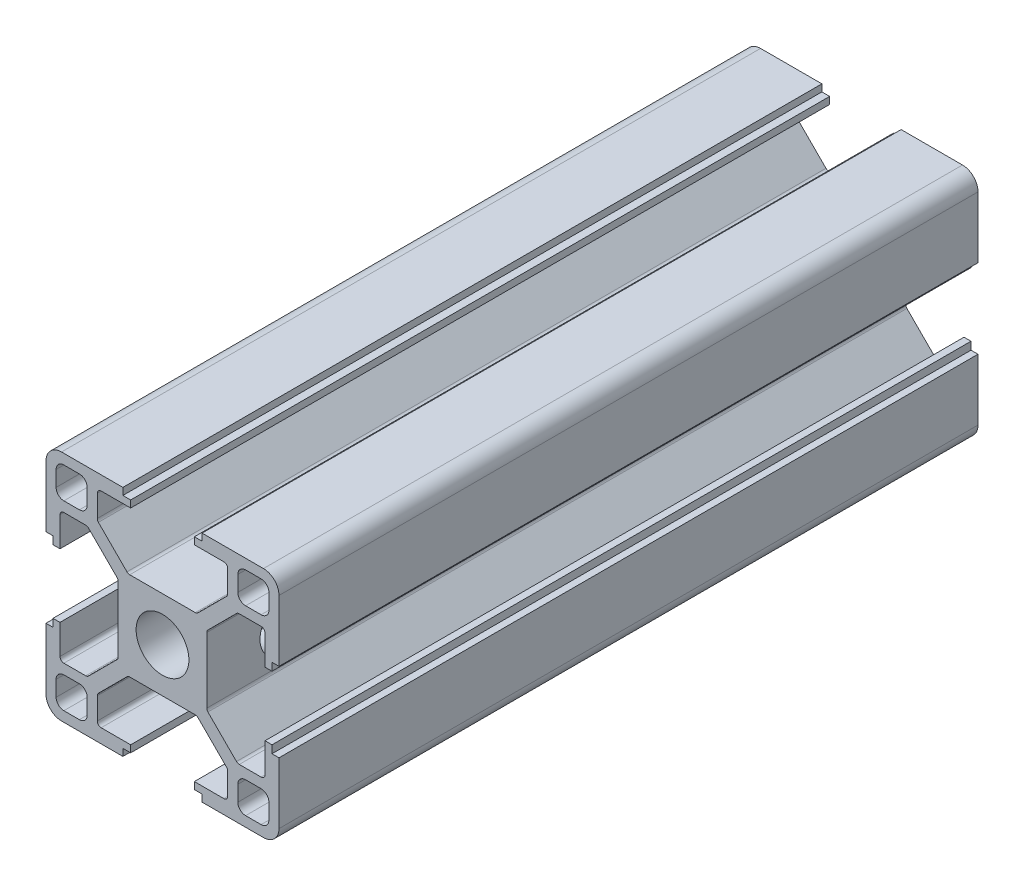
from build123d import *

# Parameters (mm, degrees)
SKETCH_1_W                       = 4
SKETCH_1_H                       = 4
EXTRUDE_1_DEPTH                  = 90
FILLET_1_R                       = 1
FILLET_2_R                       = 2
FILLET_3_R                       = 0.5
PATTERN_CIRCULAR_1_COUNT         = 4
FILLET_1_OF_PATTERN_CIRCULAR_1_R = 1
FILLET_2_OF_PATTERN_CIRCULAR_1_R = 2
FILLET_3_OF_PATTERN_CIRCULAR_1_R = 0.5
SKETCH_2_R                       = 3.4
CUT_EXTRUDE_1_DEPTH              = 91
SKETCH_3_R                       = 3.15
CUT_EXTRUDE_2_DEPTH              = 21.7


with BuildPart() as part:
    # 草图1 → 凸台-拉伸1 (new body)
    with BuildSketch(Plane.XY):
        Polygon((5.7, 0), (5.7, 4.427207794), (9.672792206, 8.4), (13.2, 8.4), (13.2, 4.1), (14.1, 4.1), (14.1, 5.1), (15, 5.1), (15, 15), (5.1, 15), (5.1, 14.1), (4.1, 14.1), (4.1, 13.2), (8.4, 13.2), (8.4, 9.672792206), (4.427207794, 5.7), (0, 5.7), (0, 0), align=None)
        with Locations((11.7, 11.7)):
            Rectangle(SKETCH_1_W, SKETCH_1_H, mode=Mode.SUBTRACT)
    extrude_1 = extrude(amount=EXTRUDE_1_DEPTH)

    # 圆角1
    fillet_1_edges = [part.edges().sort_by_distance(p)[0] for p in [
        (13.7, 9.7, 45),
        (13.7, 13.7, 45),
        (9.7, 13.7, 45),
        (9.7, 9.7, 45),
    ]]
    fillet(fillet_1_edges, radius=FILLET_1_R)

    # 圆角2
    fillet_2_edges = [part.edges().sort_by_distance(p)[0] for p in [
        (15, 15, 45),
    ]]
    fillet(fillet_2_edges, radius=FILLET_2_R)

    # 圆角3
    fillet_3_edges = [part.edges().sort_by_distance(p)[0] for p in [
        (4.427207794, 5.7, 45),
        (8.4, 9.672792206, 45),
        (8.4, 13.2, 45),
        (13.2, 8.4, 45),
        (9.672792206, 8.4, 45),
        (5.7, 4.427207794, 45),
    ]]
    fillet(fillet_3_edges, radius=FILLET_3_R)

    # 阵列(圆周)1: 凸台-拉伸1 ×4 about axis
    pattern_circular_1_axis = Axis((0, 0, 0), (0, 0, 1))
    for i in range(1, PATTERN_CIRCULAR_1_COUNT):
        add(extrude_1.rotate(pattern_circular_1_axis, i * 360 / PATTERN_CIRCULAR_1_COUNT))

    # 圆角1 of 阵列(圆周)1
    fillet_1_of_pattern_circular_1_edges = [part.edges().sort_by_distance(p)[0] for p in [
        (-9.7, 13.7, 45),
        (-13.7, 13.7, 45),
        (-13.7, 9.7, 45),
        (-9.7, 9.7, 45),
        (-13.7, -9.7, 45),
        (-13.7, -13.7, 45),
        (-9.7, -13.7, 45),
        (-9.7, -9.7, 45),
        (9.7, -13.7, 45),
        (13.7, -13.7, 45),
        (13.7, -9.7, 45),
        (9.7, -9.7, 45),
    ]]
    fillet(fillet_1_of_pattern_circular_1_edges, radius=FILLET_1_OF_PATTERN_CIRCULAR_1_R)

    # 圆角2 of 阵列(圆周)1
    fillet_2_of_pattern_circular_1_edges = [part.edges().sort_by_distance(p)[0] for p in [
        (-15, 15, 45),
        (-15, -15, 45),
        (15, -15, 45),
    ]]
    fillet(fillet_2_of_pattern_circular_1_edges, radius=FILLET_2_OF_PATTERN_CIRCULAR_1_R)

    # 圆角3 of 阵列(圆周)1
    fillet_3_of_pattern_circular_1_edges = [part.edges().sort_by_distance(p)[0] for p in [
        (-5.7, 4.427207794, 45),
        (-9.672792206, 8.4, 45),
        (-13.2, 8.4, 45),
        (-8.4, 13.2, 45),
        (-8.4, 9.672792206, 45),
        (-4.427207794, 5.7, 45),
        (-4.427207794, -5.7, 45),
        (-8.4, -9.672792206, 45),
        (-8.4, -13.2, 45),
        (-13.2, -8.4, 45),
        (-9.672792206, -8.4, 45),
        (-5.7, -4.427207794, 45),
        (5.7, -4.427207794, 45),
        (9.672792206, -8.4, 45),
        (13.2, -8.4, 45),
        (8.4, -13.2, 45),
        (8.4, -9.672792206, 45),
        (4.427207794, -5.7, 45),
    ]]
    fillet(fillet_3_of_pattern_circular_1_edges, radius=FILLET_3_OF_PATTERN_CIRCULAR_1_R)

    # 草图2 → 切除-拉伸1 (cut, through all)
    with BuildSketch(Plane.XY.offset(90)):
        Circle(SKETCH_2_R)
    extrude(amount=-CUT_EXTRUDE_1_DEPTH, mode=Mode.SUBTRACT)

    # 草图3 → 切除-拉伸2 (cut, through all)
    with BuildSketch(Plane.ZY.offset(5.7)):
        with Locations((15, 0)):
            Circle(SKETCH_3_R)
        with Locations((80, 0)):
            Circle(SKETCH_3_R)
        with Locations((31, 0)):
            Circle(SKETCH_3_R)
    extrude(amount=-CUT_EXTRUDE_2_DEPTH, mode=Mode.SUBTRACT)


solid = part.part
